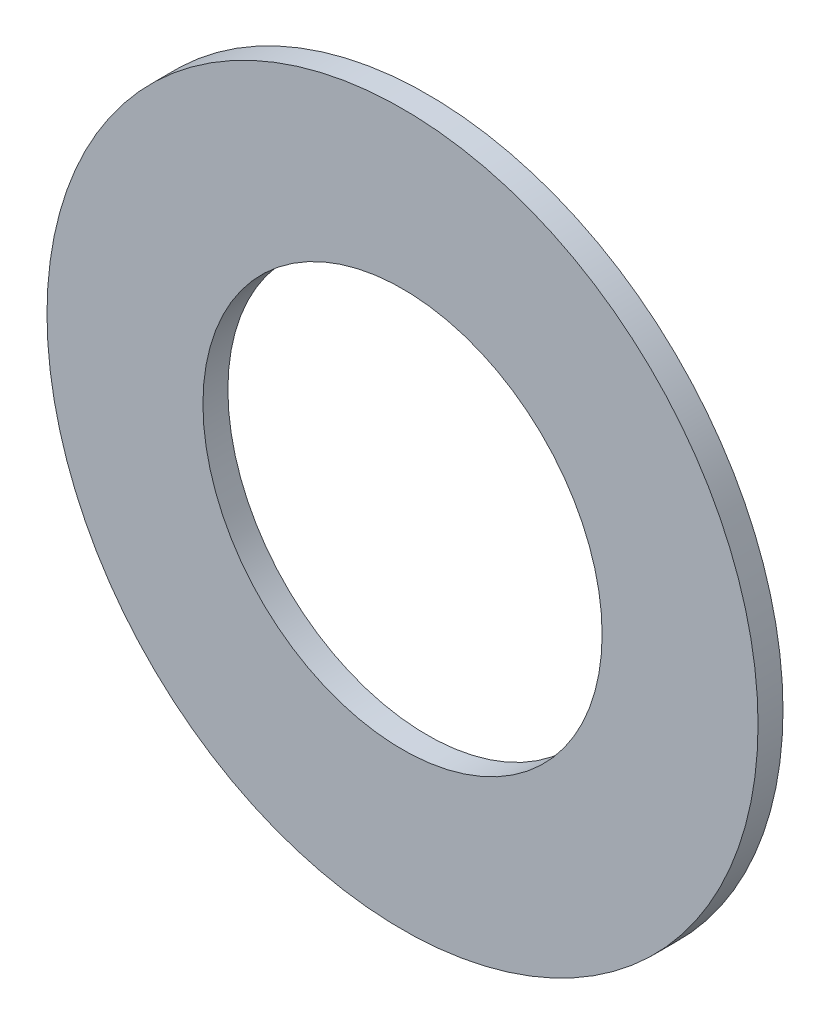
from build123d import *

# Parameters (mm, degrees)
SKETCH1_R      = 7.239
SKETCH1_R_2    = 4.064
EXTRUDE1_DEPTH = 0.508


with BuildPart() as part:
    # Sketch1 → Extrude1 (new body)
    with BuildSketch(Plane.XY):
        Circle(SKETCH1_R)
        Circle(SKETCH1_R_2, mode=Mode.SUBTRACT)
    extrude(amount=-EXTRUDE1_DEPTH)


solid = part.part
